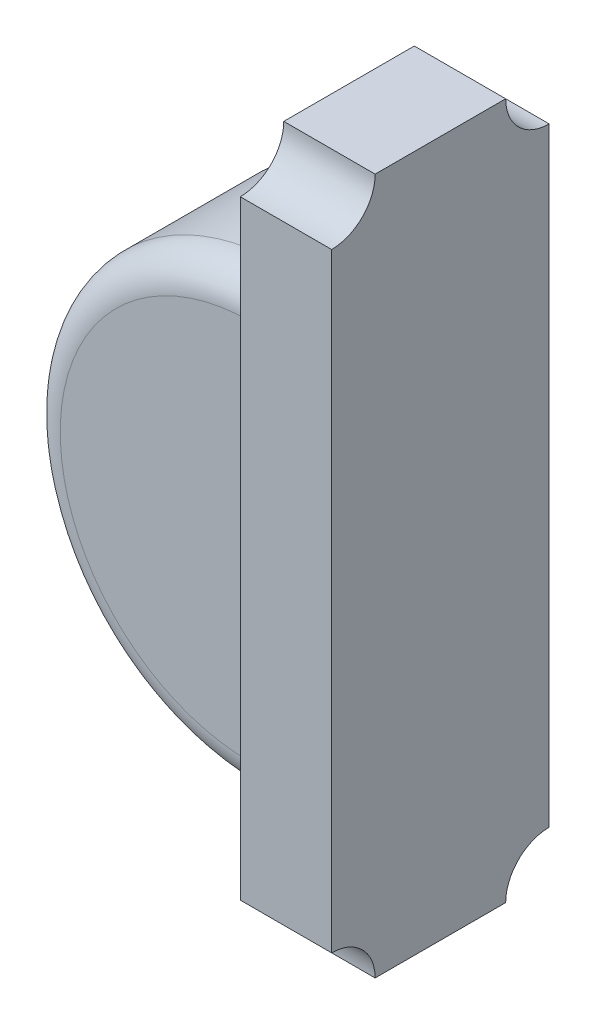
from build123d import *

# Parameters (mm, degrees)
DODANIE_WYCI_GNI_CIE1_DEPTH = 0.42
DODANIE_WYCI_GNI_CIE2_START = -0.05
DODANIE_WYCI_GNI_CIE2_DEPTH = 0.9
ZAOKR_GLENIE1_R             = 0.15


with BuildPart() as part:
    # Szkic1 → Dodanie-wyciągnięcie1 (new body)
    with BuildSketch(Plane(origin=(-41.05, 0, 0), x_dir=(0, 0, -1), z_dir=(1, 0, 0))):
        with BuildLine():
            Line((-2.400000095, -13.399999619), (-1.799999952, -13.399999619))
            ThreePointArc((-1.799999952, -13.399999619), (-1.74142138, -13.541421219), (-1.600000024, -13.600000381))
            Line((-1.600000024, -13.600000381), (-1.600000024, -16.399999619))
            ThreePointArc((-1.600000024, -16.399999619), (-1.741421625, -16.458578536), (-1.799999952, -16.600000381))
            Line((-1.799999952, -16.600000381), (-2.400000095, -16.600000381))
            ThreePointArc((-2.400000095, -16.600000381), (-2.458578346, -16.458578544), (-2.599999905, -16.399999619))
            Line((-2.599999905, -16.399999619), (-2.599999905, -13.600000381))
            ThreePointArc((-2.599999905, -13.600000381), (-2.458578346, -13.541421456), (-2.400000095, -13.399999619))
        make_face()
    extrude(amount=-DODANIE_WYCI_GNI_CIE1_DEPTH)


with BuildPart() as body_2:
    # Szkic2 → Dodanie-wyciągnięcie2 (new body)
    with BuildSketch(Plane.XY.offset(2.599999905).offset(DODANIE_WYCI_GNI_CIE2_START)):
        with BuildLine():
            Line((-41.47, -13.972591173), (-41.47, -16.027408827))
            ThreePointArc((-41.47, -16.027408827), (-42.497408827, -15), (-41.47, -13.972591173))
        make_face()
    extrude(amount=-DODANIE_WYCI_GNI_CIE2_DEPTH)

    # Zaokrąglenie1
    zaokr_glenie1_edges = [body_2.edges().sort_by_distance(p)[0] for p in [
        (-42.497408827, -15, 2.549999905),
        (-42.497408827, -15, 1.649999905),
    ]]
    fillet(zaokr_glenie1_edges, radius=ZAOKR_GLENIE1_R)


solid = Compound([part.part, body_2.part])
